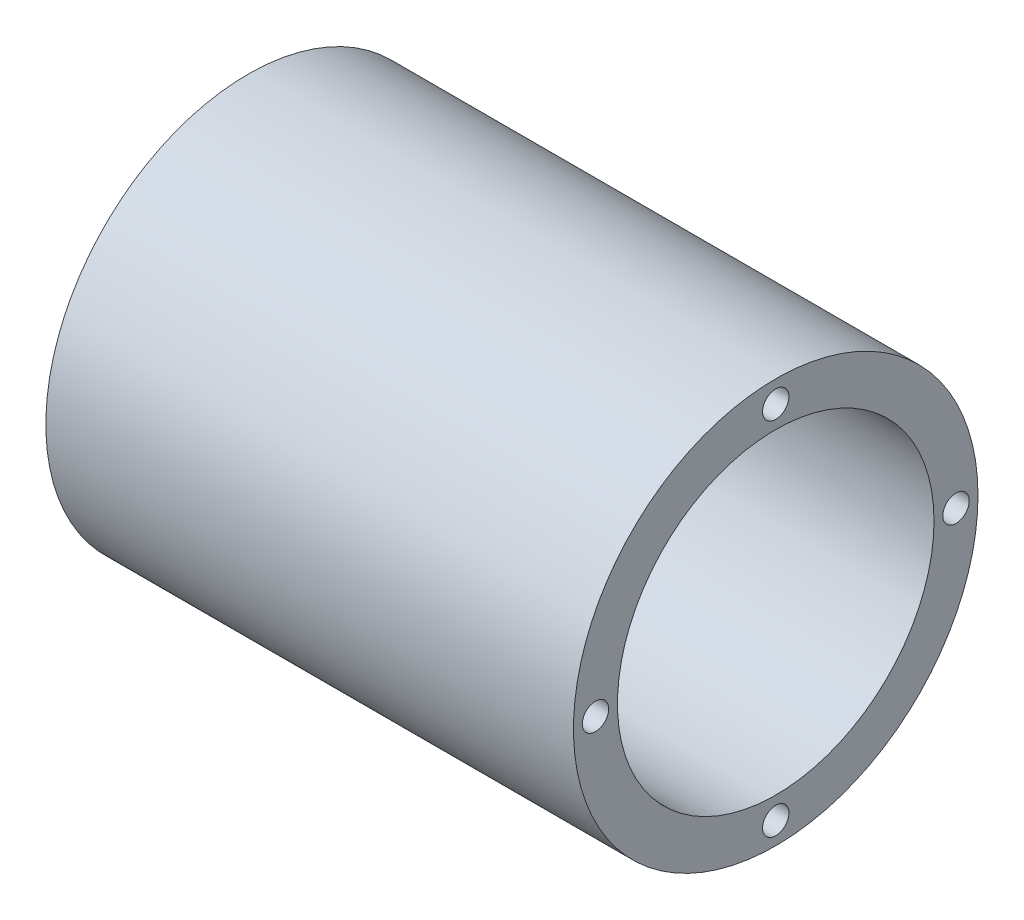
from build123d import *

# Parameters (mm, degrees)
SKETCH1_R           = 23
SKETCH1_R_2         = 18
BOSS_EXTRUDE1_DEPTH = 11
SKETCH1_13_R        = 23
SKETCH1_13_R_2      = 18
SKETCH1_13_R_3      = 3
SKETCH1_13_R_4      = 5.25
BOSS_EXTRUDE2_DEPTH = 3
BOSS_EXTRUDE4_START = 3
SKETCH1_16_R        = 23
SKETCH1_16_R_2      = 18
SKETCH1_16_R_3      = 3
SKETCH1_16_R_4      = 5.25
SKETCH1_16_R_5      = 1.5
BOSS_EXTRUDE4_DEPTH = 3
SKETCH1_17_R        = 23
SKETCH1_17_R_2      = 18
BOSS_EXTRUDE5_DEPTH = 60
SKETCH2_R           = 1.5
CUT_EXTRUDE1_DEPTH  = 5
BOSS_EXTRUDE6_START = 6
SKETCH1_20_R        = 3
SKETCH1_20_R_2      = 1.5
BOSS_EXTRUDE6_DEPTH = 3
SKETCH1_21_R        = 23
SKETCH1_21_R_2      = 18
CUT_EXTRUDE4_DEPTH  = 23
SKETCH2_2_R         = 1.5
CUT_EXTRUDE5_DEPTH  = 9


with BuildPart() as part:
    # Sketch1 → Boss-Extrude1 (new body)
    with BuildSketch(Plane(origin=(0, 0, 0), x_dir=(0, 0, -1), z_dir=(1, 0, 0))):
        Circle(SKETCH1_R)
        Circle(SKETCH1_R_2, mode=Mode.SUBTRACT)
    extrude(amount=-BOSS_EXTRUDE1_DEPTH)

    # Sketch1_13 → Boss-Extrude2 (add)
    with BuildSketch(Plane(origin=(0, 0, 0), x_dir=(0, 0, -1), z_dir=(1, 0, 0))):
        Circle(SKETCH1_13_R)
        Circle(SKETCH1_13_R_2, mode=Mode.SUBTRACT)
        Circle(SKETCH1_13_R_2)
        with Locations((-8.5, 0)):
            Circle(SKETCH1_13_R_3, mode=Mode.SUBTRACT)
        with Locations((8.5, 0)):
            Circle(SKETCH1_13_R_3, mode=Mode.SUBTRACT)
        Circle(SKETCH1_13_R_4, mode=Mode.SUBTRACT)
        with Locations((0, -8.5)):
            Circle(SKETCH1_13_R_3, mode=Mode.SUBTRACT)
        with Locations((0, 8.5)):
            Circle(SKETCH1_13_R_3, mode=Mode.SUBTRACT)
    extrude(amount=BOSS_EXTRUDE2_DEPTH)

    # Sketch1_16 → Boss-Extrude4 (add)
    with BuildSketch(Plane(origin=(0, 0, 0), x_dir=(0, 0, -1), z_dir=(1, 0, 0)).offset(BOSS_EXTRUDE4_START)):
        Circle(SKETCH1_16_R)
        Circle(SKETCH1_16_R_2, mode=Mode.SUBTRACT)
        Circle(SKETCH1_16_R_2)
        with Locations((-8.5, 0)):
            Circle(SKETCH1_16_R_3, mode=Mode.SUBTRACT)
        with Locations((8.5, 0)):
            Circle(SKETCH1_16_R_3, mode=Mode.SUBTRACT)
        Circle(SKETCH1_16_R_4, mode=Mode.SUBTRACT)
        with Locations((0, -8.5)):
            Circle(SKETCH1_16_R_3, mode=Mode.SUBTRACT)
        with Locations((0, 8.5)):
            Circle(SKETCH1_16_R_3, mode=Mode.SUBTRACT)
        with Locations((0, 8.5)):
            Circle(SKETCH1_16_R_3)
        with Locations((0, 8.5)):
            Circle(SKETCH1_16_R_5, mode=Mode.SUBTRACT)
        with Locations((-8.5, 0)):
            Circle(SKETCH1_16_R_3)
        with Locations((-8.5, 0)):
            Circle(SKETCH1_16_R_5, mode=Mode.SUBTRACT)
        with Locations((0, -8.5)):
            Circle(SKETCH1_16_R_3)
        with Locations((0, -8.5)):
            Circle(SKETCH1_16_R_5, mode=Mode.SUBTRACT)
        with Locations((8.5, 0)):
            Circle(SKETCH1_16_R_3)
        with Locations((8.5, 0)):
            Circle(SKETCH1_16_R_5, mode=Mode.SUBTRACT)
    extrude(amount=BOSS_EXTRUDE4_DEPTH)

    # Sketch1_17 → Boss-Extrude5 (add)
    with BuildSketch(Plane(origin=(0, 0, 0), x_dir=(0, 0, -1), z_dir=(1, 0, 0))):
        Circle(SKETCH1_17_R)
        Circle(SKETCH1_17_R_2, mode=Mode.SUBTRACT)
    extrude(amount=BOSS_EXTRUDE5_DEPTH)

    # Sketch2 → Cut-Extrude1 (cut)
    with BuildSketch(Plane(origin=(60, 0, 0), x_dir=(0, 0, -1), z_dir=(1, 0, 0))):
        with Locations((0, 20.5)):
            Circle(SKETCH2_R)
        with Locations((20.5, 0)):
            Circle(SKETCH2_R)
        with Locations((0, -20.5)):
            Circle(SKETCH2_R)
        with Locations((-20.5, 0)):
            Circle(SKETCH2_R)
    extrude(amount=-CUT_EXTRUDE1_DEPTH, mode=Mode.SUBTRACT)

    # Sketch1_20 → Boss-Extrude6 (add)
    with BuildSketch(Plane(origin=(0, 0, 0), x_dir=(0, 0, -1), z_dir=(1, 0, 0)).offset(BOSS_EXTRUDE6_START)):
        with Locations((0, 8.5)):
            Circle(SKETCH1_20_R)
        with Locations((0, 8.5)):
            Circle(SKETCH1_20_R_2, mode=Mode.SUBTRACT)
        with Locations((-8.5, 0)):
            Circle(SKETCH1_20_R)
        with Locations((-8.5, 0)):
            Circle(SKETCH1_20_R_2, mode=Mode.SUBTRACT)
        with Locations((0, -8.5)):
            Circle(SKETCH1_20_R)
        with Locations((0, -8.5)):
            Circle(SKETCH1_20_R_2, mode=Mode.SUBTRACT)
        with Locations((8.5, 0)):
            Circle(SKETCH1_20_R)
        with Locations((8.5, 0)):
            Circle(SKETCH1_20_R_2, mode=Mode.SUBTRACT)
    extrude(amount=-BOSS_EXTRUDE6_DEPTH)

    # Sketch1_21 → Cut-Extrude4 (cut)
    with BuildSketch(Plane(origin=(0, 0, 0), x_dir=(0, 0, -1), z_dir=(1, 0, 0))):
        Circle(SKETCH1_21_R)
        Circle(SKETCH1_21_R_2, mode=Mode.SUBTRACT)
    extrude(amount=-CUT_EXTRUDE4_DEPTH, mode=Mode.SUBTRACT)

    # Sketch2_2 → Cut-Extrude5 (cut)
    with BuildSketch(Plane(origin=(60, 0, 0), x_dir=(0, 0, -1), z_dir=(1, 0, 0))):
        with Locations((0, 20.5)):
            Circle(SKETCH2_2_R)
        with Locations((20.5, 0)):
            Circle(SKETCH2_2_R)
        with Locations((0, -20.5)):
            Circle(SKETCH2_2_R)
        with Locations((-20.5, 0)):
            Circle(SKETCH2_2_R)
    extrude(amount=-CUT_EXTRUDE5_DEPTH, mode=Mode.SUBTRACT)


solid = part.part
